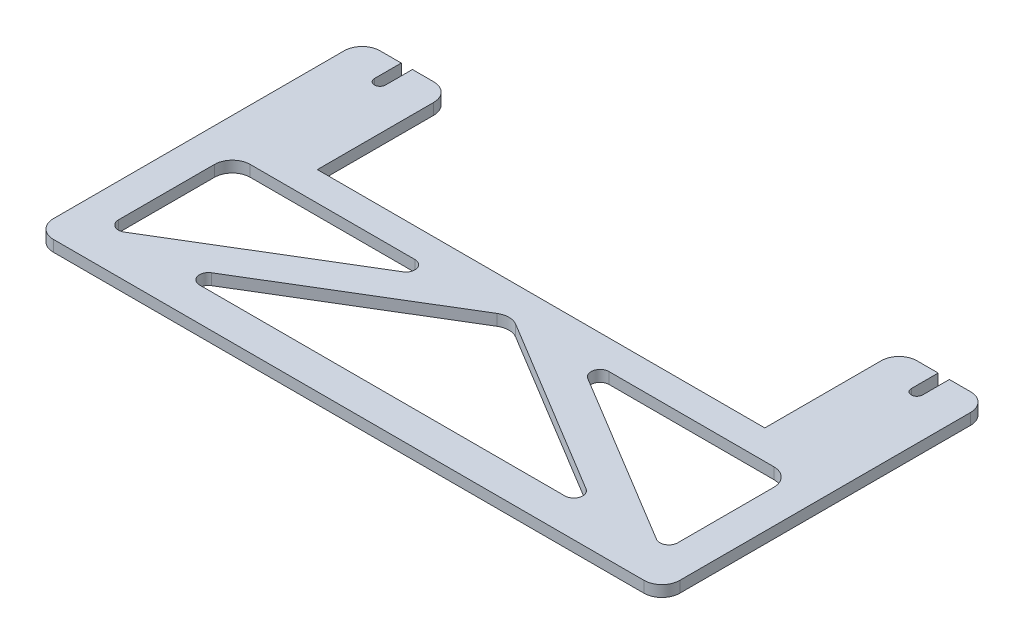
from build123d import *

# Parameters (mm, degrees)
SKETCH1_W           = 177.8
SKETCH1_H           = 67.31
BOSS_EXTRUDE1_DEPTH = 3.175
CUT_EXTRUDE1_DEPTH  = 4.175
CUT_EXTRUDE2_DEPTH  = 4.175
SKETCH5_W           = 127
SKETCH5_H           = 12.7
CUT_EXTRUDE3_DEPTH  = 4.175
FILLET1_R           = 5.08
FILLET2_R           = 2.54
SKETCH7_W           = 25.4
SKETCH7_H           = 38.1
BOSS_EXTRUDE2_DEPTH = 3.175
CUT_EXTRUDE4_DEPTH  = 4.175
FILLET3_R           = 5.08


with BuildPart() as part:
    # Sketch1 → Boss-Extrude1 (new body)
    with BuildSketch(Plane(origin=(0, 0, 0), x_dir=(1, 0, 0), z_dir=(0, 1, 0))):
        with Locations((88.9, 33.655)):
            Rectangle(SKETCH1_W, SKETCH1_H)
    extrude(amount=BOSS_EXTRUDE1_DEPTH)

    # Sketch3 → Cut-Extrude1 (cut, through all)
    with BuildSketch(Plane(origin=(0, 3.175, 0), x_dir=(1, 0, 0), z_dir=(0, 1, 0))):
        Polygon((88.9, 46.355), (27.943666175, 9.525), (149.856333825, 9.525), align=None)
        Polygon((9.525, 46.355), (9.525, 9.525), (70.481333825, 46.355), align=None)
        Polygon((168.275, 9.525), (107.318666175, 46.355), (168.275, 46.355), align=None)
    extrude(amount=-CUT_EXTRUDE1_DEPTH, mode=Mode.SUBTRACT)

    # Sketch4 → Cut-Extrude2 (cut, through all)
    with BuildSketch(Plane(origin=(0, 3.175, 0), x_dir=(1, 0, 0), z_dir=(0, 1, 0))):
        with BuildLine():
            Line((11.1125, 67.31), (11.1125, 62.23))
            ThreePointArc((11.1125, 62.23), (12.7, 60.6425), (14.2875, 62.23))
            Line((14.2875, 62.23), (14.2875, 67.31))
            Line((14.2875, 67.31), (11.1125, 67.31))
        make_face()
        with BuildLine():
            Line((166.6875, 67.31), (166.6875, 62.23))
            ThreePointArc((166.6875, 62.23), (165.1, 60.6425), (163.5125, 62.23))
            Line((163.5125, 62.23), (163.5125, 67.31))
            Line((163.5125, 67.31), (166.6875, 67.31))
        make_face()
    extrude(amount=-CUT_EXTRUDE2_DEPTH, mode=Mode.SUBTRACT)

    # Sketch5 → Cut-Extrude3 (cut, through all)
    with BuildSketch(Plane(origin=(0, 3.175, 0), x_dir=(1, 0, 0), z_dir=(0, 1, 0))):
        with Locations((88.9, 60.96)):
            Rectangle(SKETCH5_W, SKETCH5_H)
    extrude(amount=-CUT_EXTRUDE3_DEPTH, mode=Mode.SUBTRACT)

    # Fillet1
    fillet1_edges = [part.edges().sort_by_distance(p)[0] for p in [
        (88.9, 1.5875, -46.355),
        (9.525, 1.5875, -46.355),
        (168.275, 1.5875, -46.355),
        (0, 1.5875, -67.31),
        (177.8, 1.5875, -67.31),
        (177.8, 1.5875, 0),
        (0, 1.5875, 0),
        (25.4, 1.5875, -67.31),
        (152.4, 1.5875, -67.31),
    ]]
    fillet(fillet1_edges, radius=FILLET1_R)

    # Fillet2
    fillet2_edges = [part.edges().sort_by_distance(p)[0] for p in [
        (149.856333825, 1.5875, -9.525),
        (27.943666175, 1.5875, -9.525),
        (70.481333825, 1.5875, -46.355),
        (9.525, 1.5875, -9.525),
        (168.275, 1.5875, -9.525),
        (107.318666175, 1.5875, -46.355),
    ]]
    fillet(fillet2_edges, radius=FILLET2_R)

    # Sketch7 → Boss-Extrude2 (add)
    with BuildSketch(Plane(origin=(0, 3.175, 0), x_dir=(1, 0, 0), z_dir=(0, 1, 0))):
        with Locations((12.7, 73.66)):
            Rectangle(SKETCH7_W, SKETCH7_H)
        with Locations((165.1, 73.66)):
            Rectangle(SKETCH7_W, SKETCH7_H)
    extrude(amount=-BOSS_EXTRUDE2_DEPTH)

    # Sketch8 → Cut-Extrude4 (cut, through all)
    with BuildSketch(Plane(origin=(0, 3.175, 0), x_dir=(1, 0, 0), z_dir=(0, 1, 0))):
        with BuildLine():
            Line((11.1125, 92.71), (11.1125, 85.09))
            ThreePointArc((11.1125, 85.09), (12.7, 83.5025), (14.2875, 85.09))
            Line((14.2875, 85.09), (14.2875, 92.71))
            Line((14.2875, 92.71), (11.1125, 92.71))
        make_face()
        with BuildLine():
            Line((163.5125, 85.09), (163.5125, 92.71))
            Line((163.5125, 92.71), (166.6875, 92.71))
            Line((166.6875, 92.71), (166.6875, 85.09))
            ThreePointArc((166.6875, 85.09), (165.1, 83.5025), (163.5125, 85.09))
        make_face()
    extrude(amount=-CUT_EXTRUDE4_DEPTH, mode=Mode.SUBTRACT)

    # Fillet3
    fillet3_edges = [part.edges().sort_by_distance(p)[0] for p in [
        (25.4, 1.5875, -92.71),
        (0, 1.5875, -92.71),
        (177.8, 1.5875, -92.71),
        (152.4, 1.5875, -92.71),
    ]]
    fillet(fillet3_edges, radius=FILLET3_R)


solid = part.part
